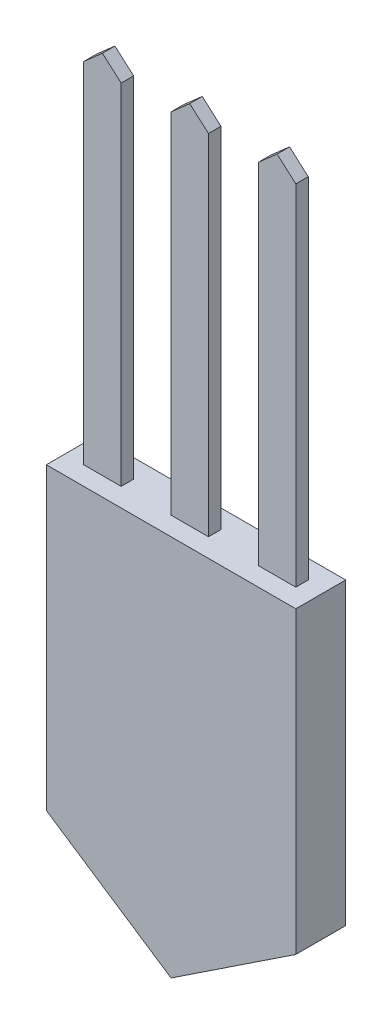
from build123d import *

# Parameters (mm, degrees)
SKETCH1_W           = 63.5
SKETCH1_H           = 12.7
BOSS_EXTRUDE1_DEPTH = 76.2
SKETCH2_W           = 9.525
SKETCH2_H           = 3.175
BOSS_EXTRUDE2_DEPTH = 88.9
BOSS_EXTRUDE3_DEPTH = 3.175
BOSS_EXTRUDE4_DEPTH = 12.7


with BuildPart() as part:
    # Sketch1 → Boss-Extrude1 (new body)
    with BuildSketch(Plane(origin=(0, 0, 0), x_dir=(1, 0, 0), z_dir=(0, 1, 0))):
        Rectangle(SKETCH1_W, SKETCH1_H)
    extrude(amount=BOSS_EXTRUDE1_DEPTH)

    # Sketch2 → Boss-Extrude2 (add)
    with BuildSketch(Plane(origin=(0, 76.2, 0), x_dir=(1, 0, 0), z_dir=(0, 1, 0))):
        Rectangle(SKETCH2_W, SKETCH2_H)
        with Locations((-22.225, 0)):
            Rectangle(SKETCH2_W, SKETCH2_H)
        with Locations((22.225, 0)):
            Rectangle(SKETCH2_W, SKETCH2_H)
    extrude(amount=BOSS_EXTRUDE2_DEPTH)

    # Sketch3 → Boss-Extrude3 (add)
    with BuildSketch(Plane(origin=(0, 0, -1.5875), x_dir=(-1, 0, 0), z_dir=(0, 0, -1))):
        Polygon((-26.9875, 165.1), (-17.4625, 165.1), (-22.225, 169.300130206), align=None)
        Polygon((-4.7625, 165.1), (4.7625, 165.1), (0, 169.300130206), align=None)
        Polygon((17.4625, 165.1), (26.9875, 165.1), (22.225, 169.300130206), align=None)
    extrude(amount=-BOSS_EXTRUDE3_DEPTH)

    # Sketch4 → Boss-Extrude4 (add)
    with BuildSketch(Plane.XY.offset(6.35)):
        Polygon((31.75, 0), (0, -21.060567419), (-31.75, 0), align=None)
    extrude(amount=-BOSS_EXTRUDE4_DEPTH)


solid = part.part
